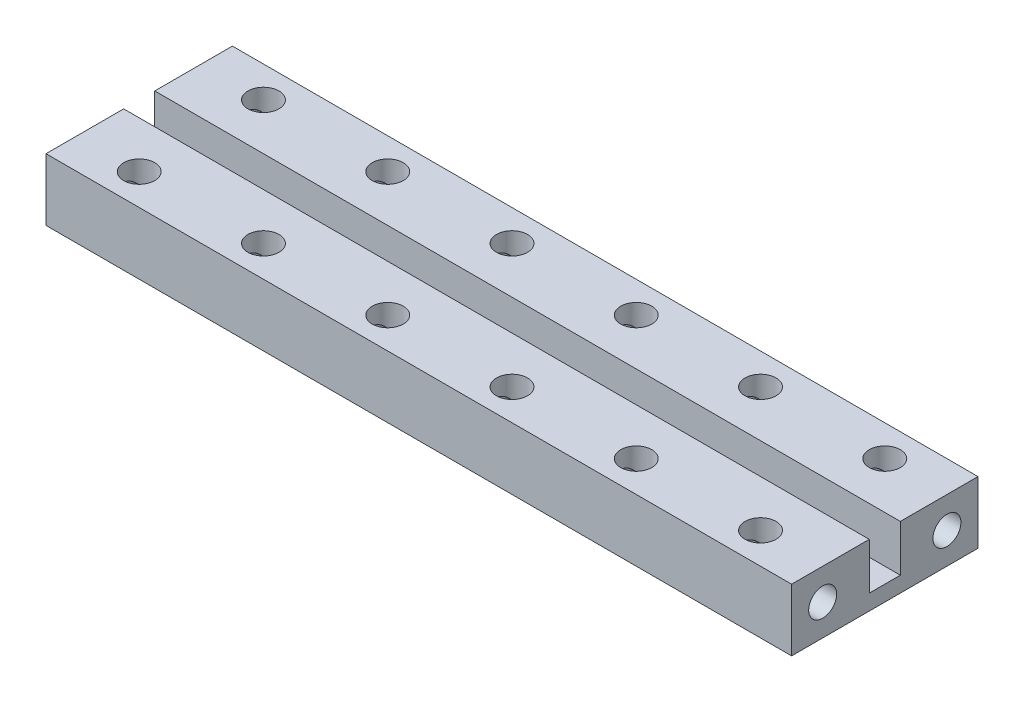
from build123d import *

# Parameters (mm, degrees)
SKETCH_1_W          = 96
SKETCH_1_H          = 24
EXTRUDE_1_DEPTH     = 8
SKETCH_2_W          = 96
SKETCH_2_H          = 4
CUT_EXTRUDE_1_DEPTH = 6
SKETCH_3_R          = 1.8
CUT_EXTRUDE_2_DEPTH = 97
SKETCH_4_R          = 2
CUT_EXTRUDE_3_DEPTH = 9


with BuildPart() as part:
    # 스케치1 → 보스-돌출1 (new body)
    with BuildSketch(Plane(origin=(0, 0, 0), x_dir=(1, 0, 0), z_dir=(0, 1, 0))):
        Rectangle(SKETCH_1_W, SKETCH_1_H)
    extrude(amount=EXTRUDE_1_DEPTH)

    # 스케치2 → 컷-돌출1 (cut)
    with BuildSketch(Plane(origin=(0, 8, 0), x_dir=(1, 0, 0), z_dir=(0, 1, 0))):
        Rectangle(SKETCH_2_W, SKETCH_2_H)
    extrude(amount=-CUT_EXTRUDE_1_DEPTH, mode=Mode.SUBTRACT)

    # 스케치3 → 컷-돌출2 (cut, through all)
    with BuildSketch(Plane.ZY.offset(48)):
        with Locations((-8, 4)):
            Circle(SKETCH_3_R)
        with Locations((8, 4)):
            Circle(SKETCH_3_R)
    extrude(amount=-CUT_EXTRUDE_2_DEPTH, mode=Mode.SUBTRACT)

    # 스케치4 → 컷-돌출3 (cut, through all)
    with BuildSketch(Plane(origin=(0, 8, 0), x_dir=(1, 0, 0), z_dir=(0, 1, 0))):
        with Locations((-40, 8)):
            Circle(SKETCH_4_R)
        with Locations((-24, 8)):
            Circle(SKETCH_4_R)
        with Locations((-40, -8)):
            Circle(SKETCH_4_R)
        with Locations((-24, -8)):
            Circle(SKETCH_4_R)
        with Locations((-8, 8)):
            Circle(SKETCH_4_R)
        with Locations((-8, -8)):
            Circle(SKETCH_4_R)
        with Locations((8, 8)):
            Circle(SKETCH_4_R)
        with Locations((8, -8)):
            Circle(SKETCH_4_R)
        with Locations((24, 8)):
            Circle(SKETCH_4_R)
        with Locations((24, -8)):
            Circle(SKETCH_4_R)
        with Locations((40, -8)):
            Circle(SKETCH_4_R)
        with Locations((40, 8)):
            Circle(SKETCH_4_R)
    extrude(amount=-CUT_EXTRUDE_3_DEPTH, mode=Mode.SUBTRACT)


solid = part.part
